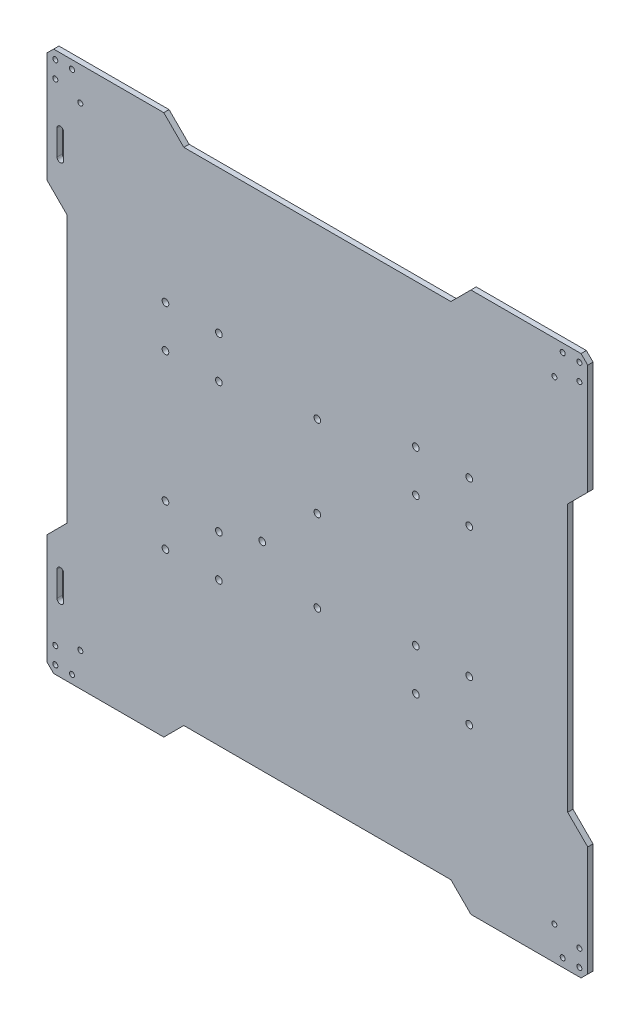
from build123d import *

# Parameters (mm, degrees)
SKETCH1_R           = 1.5
SKETCH1_R_2         = 2
BOSS_EXTRUDE1_DEPTH = 3.175
CUT_EXTRUDE1_DEPTH  = 4.175
CHAMFER1_SIZE       = 4


with BuildPart() as part:
    # Sketch1 → Boss-Extrude1 (new body)
    with BuildSketch(Plane.XY):
        Polygon((162, 162), (162, 92), (150, 80), (150, -80), (162, -92), (162, -162), (92, -162), (80, -150), (-80, -150), (-92, -162), (-162, -162), (-162, -92), (-150, -80), (-150, 80), (-162, 92), (-162, 162), (-92, 162), (-80, 150), (80, 150), (92, 162), align=None)
        with Locations((-157, 157)):
            Circle(SKETCH1_R, mode=Mode.SUBTRACT)
        with Locations((157, 157)):
            Circle(SKETCH1_R, mode=Mode.SUBTRACT)
        with Locations((157, -157)):
            Circle(SKETCH1_R, mode=Mode.SUBTRACT)
        with Locations((-157, -157)):
            Circle(SKETCH1_R, mode=Mode.SUBTRACT)
        with Locations((-91, 64)):
            Circle(SKETCH1_R_2, mode=Mode.SUBTRACT)
        with Locations((-91, 39)):
            Circle(SKETCH1_R_2, mode=Mode.SUBTRACT)
        with Locations((-59, 39)):
            Circle(SKETCH1_R_2, mode=Mode.SUBTRACT)
        with Locations((-59, 64)):
            Circle(SKETCH1_R_2, mode=Mode.SUBTRACT)
        with Locations((59, 39)):
            Circle(SKETCH1_R_2, mode=Mode.SUBTRACT)
        with Locations((59, 64)):
            Circle(SKETCH1_R_2, mode=Mode.SUBTRACT)
        with Locations((91, 39)):
            Circle(SKETCH1_R_2, mode=Mode.SUBTRACT)
        with Locations((91, 64)):
            Circle(SKETCH1_R_2, mode=Mode.SUBTRACT)
        with Locations((59, -64)):
            Circle(SKETCH1_R_2, mode=Mode.SUBTRACT)
        with Locations((59, -39)):
            Circle(SKETCH1_R_2, mode=Mode.SUBTRACT)
        with Locations((91, -39)):
            Circle(SKETCH1_R_2, mode=Mode.SUBTRACT)
        with Locations((91, -64)):
            Circle(SKETCH1_R_2, mode=Mode.SUBTRACT)
        with Locations((-91, -64)):
            Circle(SKETCH1_R_2, mode=Mode.SUBTRACT)
        with Locations((-59, -64)):
            Circle(SKETCH1_R_2, mode=Mode.SUBTRACT)
        with Locations((-59, -39)):
            Circle(SKETCH1_R_2, mode=Mode.SUBTRACT)
        with Locations((-91, -39)):
            Circle(SKETCH1_R_2, mode=Mode.SUBTRACT)
        with Locations((-33, -31)):
            Circle(SKETCH1_R_2, mode=Mode.SUBTRACT)
        Circle(SKETCH1_R_2, mode=Mode.SUBTRACT)
        with Locations((0, 49)):
            Circle(SKETCH1_R_2, mode=Mode.SUBTRACT)
        with Locations((0, -49)):
            Circle(SKETCH1_R_2, mode=Mode.SUBTRACT)
        with Locations((-147, 157)):
            Circle(SKETCH1_R, mode=Mode.SUBTRACT)
        with Locations((-157, 147)):
            Circle(SKETCH1_R, mode=Mode.SUBTRACT)
        with Locations((147, 157)):
            Circle(SKETCH1_R, mode=Mode.SUBTRACT)
        with Locations((157, 147)):
            Circle(SKETCH1_R, mode=Mode.SUBTRACT)
        with Locations((157, -147)):
            Circle(SKETCH1_R, mode=Mode.SUBTRACT)
        with Locations((147, -157)):
            Circle(SKETCH1_R, mode=Mode.SUBTRACT)
        with Locations((-147, -157)):
            Circle(SKETCH1_R, mode=Mode.SUBTRACT)
        with Locations((-157, -147)):
            Circle(SKETCH1_R, mode=Mode.SUBTRACT)
        with Locations((-142, 142)):
            Circle(SKETCH1_R, mode=Mode.SUBTRACT)
        with Locations((142, 142)):
            Circle(SKETCH1_R, mode=Mode.SUBTRACT)
        with Locations((142, -142)):
            Circle(SKETCH1_R, mode=Mode.SUBTRACT)
        with Locations((-142, -142)):
            Circle(SKETCH1_R, mode=Mode.SUBTRACT)
    extrude(amount=BOSS_EXTRUDE1_DEPTH)

    # Sketch2 → Cut-Extrude1 (cut, through all)
    with BuildSketch(Plane.XY.offset(3.175)):
        with BuildLine():
            Line((-156, 122), (-156, 107))
            ThreePointArc((-156, 107), (-154, 105), (-152, 107))
            Line((-152, 107), (-152, 122))
            ThreePointArc((-152, 122), (-154, 124), (-156, 122))
        make_face()
        with BuildLine():
            Line((-152, -107), (-152, -122))
            ThreePointArc((-152, -122), (-154, -124), (-156, -122))
            Line((-156, -122), (-156, -107))
            ThreePointArc((-156, -107), (-154, -105), (-152, -107))
        make_face()
    extrude(amount=-CUT_EXTRUDE1_DEPTH, mode=Mode.SUBTRACT)

    # Chamfer1
    chamfer1_edges = [part.edges().sort_by_distance(p)[0] for p in [
        (162, -162, 1.5875),
        (-162, -162, 1.5875),
        (-162, 162, 1.5875),
        (162, 162, 1.5875),
    ]]
    chamfer(chamfer1_edges, length=CHAMFER1_SIZE)


solid = part.part
